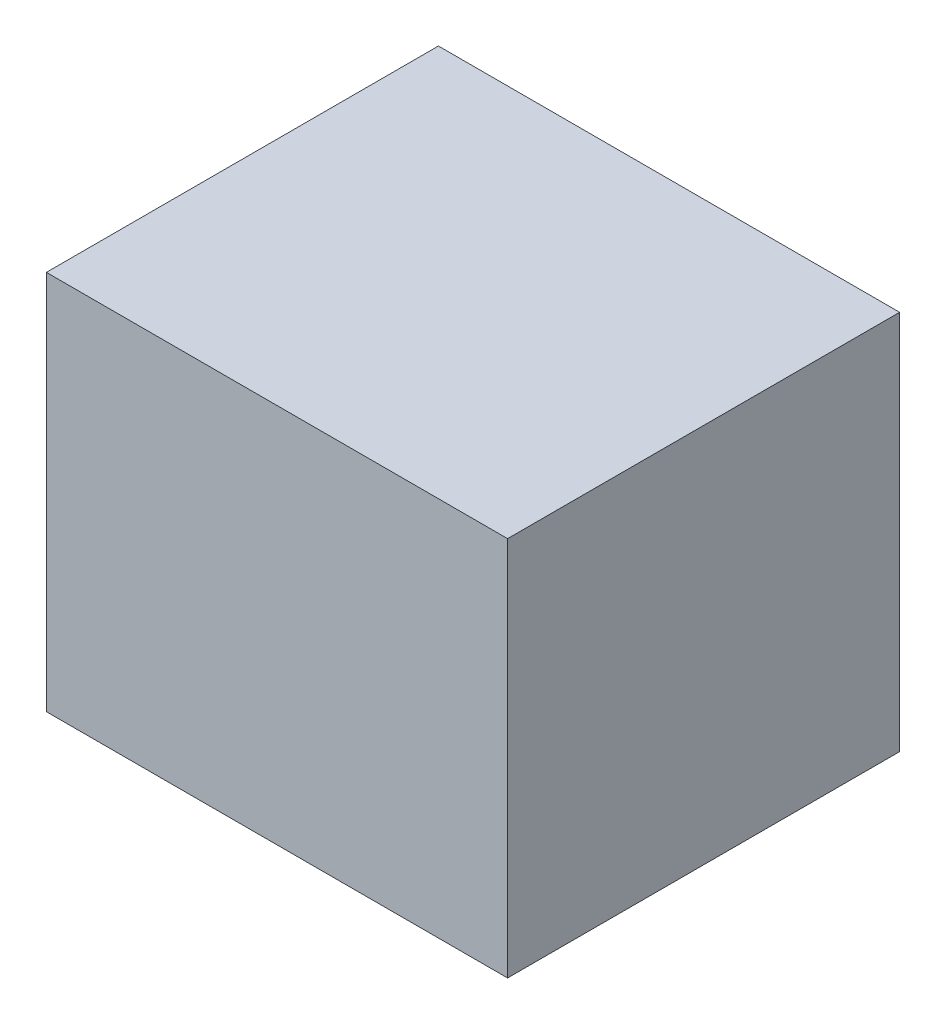
from build123d import *

# Parameters (mm, degrees)
SKETCH_1_W      = 200
SKETCH_1_H      = 165
EXTRUDE_1_DEPTH = 170


with BuildPart() as part:
    # 草圖1 → 填料-伸長1 (new body)
    with BuildSketch(Plane.XY):
        with Locations((13.099568544, -22.28021978)):
            Rectangle(SKETCH_1_W, SKETCH_1_H)
    extrude(amount=EXTRUDE_1_DEPTH)


solid = part.part
